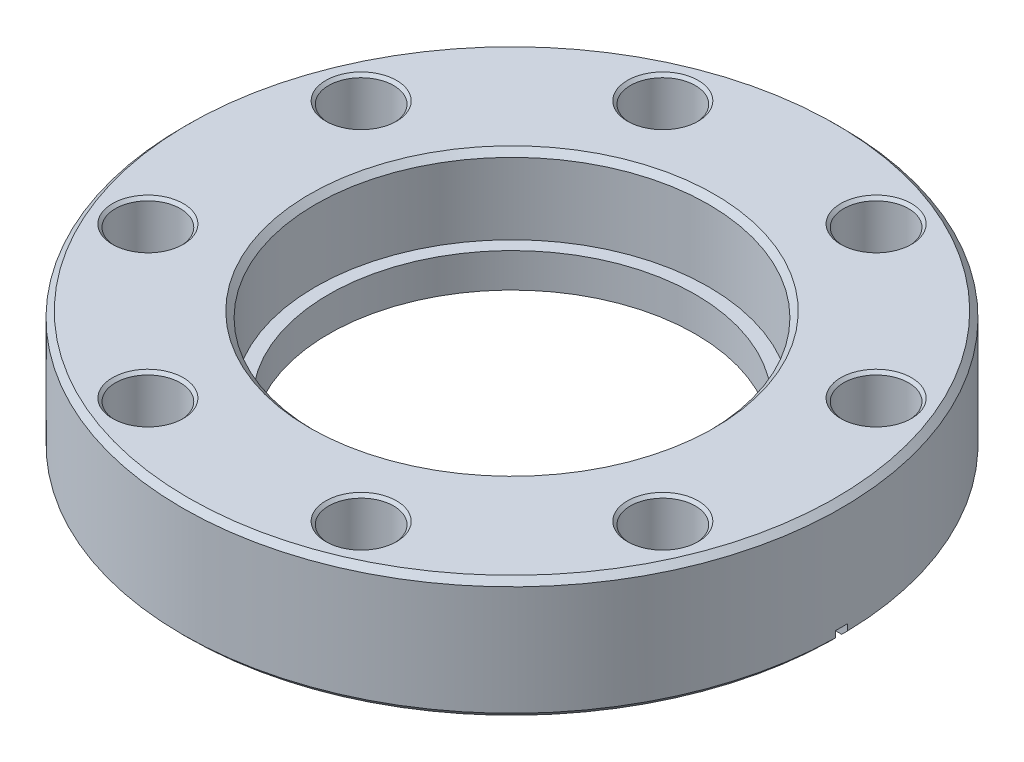
from build123d import *

# Parameters (mm, degrees)
SKETCH1_R                    = 42.799
SKETCH1_R_2                  = 23.8125
BOSS_EXTRUDE1_DEPTH          = 15.748
SKETCH2_R                    = 25.527
CUT_EXTRUDE1_DEPTH           = 10.033
CHAMFER1_SIZE                = 0.762
SKETCH3_R                    = 4.2164
CUT_EXTRUDE2_DEPTH           = 16.748
CHAMFER2_SIZE                = 0.381
CIRPATTERN1_COUNT            = 8
CHAMFER2_OF_CIRPATTERN1_SIZE = 0.381
CUT_EXTRUDE3_DEPTH           = 0.79375


with BuildPart() as part:
    # Sketch1 → Boss-Extrude1 (new body)
    with BuildSketch(Plane(origin=(0, 0, 0), x_dir=(1, 0, 0), z_dir=(0, 1, 0))):
        Circle(SKETCH1_R)
        Circle(SKETCH1_R_2, mode=Mode.SUBTRACT)
    extrude(amount=BOSS_EXTRUDE1_DEPTH)

    # Sketch2 → Cut-Extrude1 (cut)
    with BuildSketch(Plane(origin=(0, 15.748, 0), x_dir=(-1, 0, 0), z_dir=(0, 1, 0))):
        Circle(SKETCH2_R)
    extrude(amount=-CUT_EXTRUDE1_DEPTH, mode=Mode.SUBTRACT)

    # Chamfer1
    chamfer1_edges = [part.edges().sort_by_distance(p)[0] for p in [
        (25.527, 15.748, 0),
        (-42.799, 0, 0),
        (-42.799, 15.748, 0),
    ]]
    chamfer(chamfer1_edges, length=CHAMFER1_SIZE)

    # Sketch5 → Cut-Revolve1 (revolve, cut)
    with BuildSketch(Plane(origin=(0, 0, 0), x_dir=(1, 0, 0), z_dir=(0, 0, -1))):
        Polygon((0, 0), (-30.9499, 0), (-30.9499, -1.75514), (-27.94, -0.6604), (-27.94, -1.27), (0, -1.27), align=None)
    revolve(axis=Axis((0, 15.748, 0), (0, -1, 0)), mode=Mode.SUBTRACT)

    # Sketch3 → Cut-Extrude2 (cut, through all)
    with BuildSketch(Plane.XZ):
        with Locations((-13.851226834, 33.439819679)):
            Circle(SKETCH3_R)
    cut_extrude2 = extrude(amount=-CUT_EXTRUDE2_DEPTH, mode=Mode.SUBTRACT)

    # Chamfer2
    chamfer2_edges = [part.edges().sort_by_distance(p)[0] for p in [
        (-18.067626834, 15.748, 33.439819679),
        (-18.067626834, 0, 33.439819679),
    ]]
    chamfer(chamfer2_edges, length=CHAMFER2_SIZE)

    # CirPattern1: Cut-Extrude2 ×8 about axis
    cirpattern1_axis = Axis((0, 0, 0), (0, 1, 0))
    for i in range(1, CIRPATTERN1_COUNT):
        add(cut_extrude2.rotate(cirpattern1_axis, i * 360 / CIRPATTERN1_COUNT), mode=Mode.SUBTRACT)

    # Chamfer2 of CirPattern1
    chamfer2_of_cirpattern1_edges = [part.edges().sort_by_distance(p)[0] for p in [
        (10.869781802, 15.748, 36.421264711),
        (10.869781802, 0, 36.421264711),
        (33.439819679, 15.748, 18.067626834),
        (33.439819679, 0, 18.067626834),
        (36.421264711, 15.748, -10.869781802),
        (36.421264711, 0, -10.869781802),
        (18.067626834, 15.748, -33.439819679),
        (18.067626834, 0, -33.439819679),
        (-10.869781802, 15.748, -36.421264711),
        (-10.869781802, 0, -36.421264711),
        (-33.439819679, 15.748, -18.067626834),
        (-33.439819679, 0, -18.067626834),
        (-36.421264711, 15.748, 10.869781802),
        (-36.421264711, 0, 10.869781802),
    ]]
    chamfer(chamfer2_of_cirpattern1_edges, length=CHAMFER2_OF_CIRPATTERN1_SIZE)

    # Sketch6 → Cut-Extrude3 (cut, symmetric)
    with BuildSketch(Plane.XY):
        Polygon((-42.799, 1.587408258), (-42.799, -0.655592288), (-30.127480656, -0.655592288), (-30.127480656, 0.923322069), align=None)
        Polygon((30.127480656, 0.923322069), (42.799, 1.587408258), (42.799, -0.655592288), (30.127480656, -0.655592288), align=None)
    extrude(amount=CUT_EXTRUDE3_DEPTH, both=True, mode=Mode.SUBTRACT)


solid = part.part
